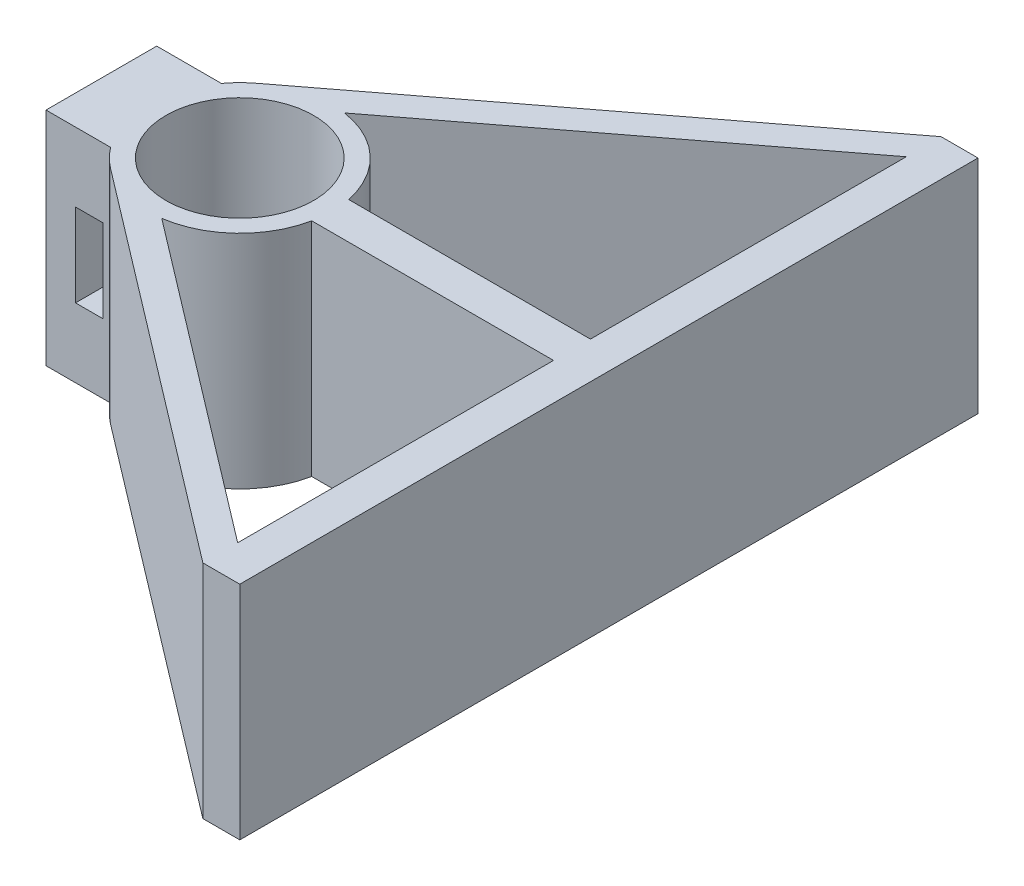
from build123d import *

# Parameters (mm, degrees)
BOSS_EXTRUDE1_DEPTH      = 6
BOSS_EXTRUDE1_DEPTH_BACK = 6
SKETCH1_R                = 4
SKETCH2_W                = 1.5
SKETCH2_H                = 4.5
CUT_EXTRUDE1_DEPTH       = 32.064449134


with BuildPart() as part:
    # Sketch1 → Boss-Extrude1 (new, two sides: drawn at the far end of the back side and taken through both)
    with BuildSketch(Plane(origin=(0, 0, 0), x_dir=(1, 0, 0), z_dir=(0, 1, 0)).offset(-BOSS_EXTRUDE1_DEPTH_BACK)):
        with BuildLine():
            Line((-4, 3), (-7.5, 3))
            Line((-7.5, 3), (-7.5, -3))
            Line((-7.5, -3), (-4, -3))
            ThreePointArc((-4, -3), (-3.548890872, -3.522126287), (-3.030194493, -3.977175044))
            Line((-3.030194493, -3.977175044), (18, -20))
            Line((18, -20), (20, -20))
            Line((20, -20), (20, -1.905552368))
            Line((20, -1.905552368), (20, 20))
            Line((20, 20), (18, 20))
            Line((18, 20), (-3.030194493, 3.977175044))
            ThreePointArc((-3.030194493, 3.977175044), (-3.548890872, 3.522126287), (-4, 3))
        make_face()
        Circle(SKETCH1_R, mode=Mode.SUBTRACT)
        with BuildLine():
            Line((4.898979486, 1), (18, 1))
            Line((18, 1), (18, 18.114239399))
            Line((18, 18.114239399), (0.719134947, 4.948014241))
            ThreePointArc((0.719134947, 4.948014241), (3.433293835, 3.634899372), (4.898979486, 1))
        make_face(mode=Mode.SUBTRACT)
        with BuildLine():
            Line((4.898979486, -1), (18, -1))
            Line((18, -1), (18, -18.114239399))
            Line((18, -18.114239399), (0.719134947, -4.948014241))
            ThreePointArc((0.719134947, -4.948014241), (3.433293835, -3.634899372), (4.898979486, -1))
        make_face(mode=Mode.SUBTRACT)
    extrude(amount=BOSS_EXTRUDE1_DEPTH + BOSS_EXTRUDE1_DEPTH_BACK)

    # Sketch2 → Cut-Extrude1 (cut, through all)
    with BuildSketch(Plane(origin=(0, 0, -3), x_dir=(-1, 0, 0), z_dir=(0, 0, -1))):
        with Locations((5.15, 0)):
            Rectangle(SKETCH2_W, SKETCH2_H)
    extrude(amount=-CUT_EXTRUDE1_DEPTH, mode=Mode.SUBTRACT)


solid = part.part
